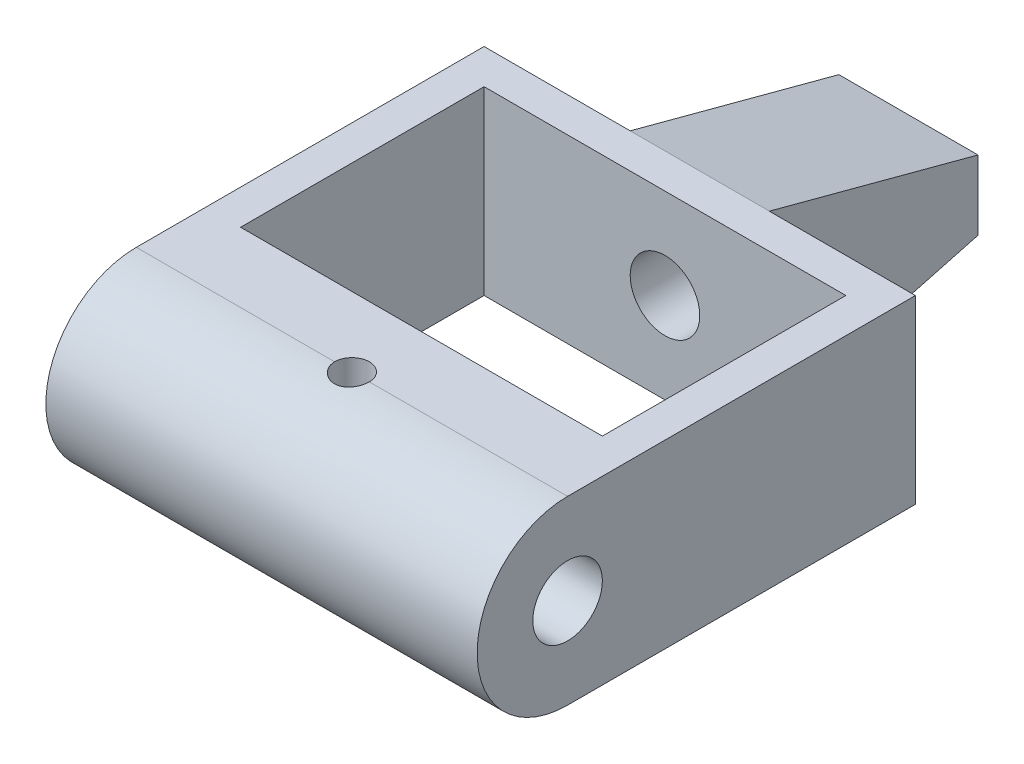
from build123d import *

# Parameters (mm, degrees)
CROQUIS1_R                 = 13
SALIENTE_EXTRUIR1_DEPTH    = 62
CROQUIS2_R                 = 5
CORTAR_EXTRUIR1_DEPTH      = 62
CORTAR_EXTRUIR2_DEPTH      = 62
CORTAR_EXTRUIR2_DEPTH_BACK = 62
CROQUIS3_R                 = 2.5
SALIENTE_EXTRUIR2_START    = -62
SALIENTE_EXTRUIR2_DEPTH    = 62
CROQUIS5_W                 = 52
CROQUIS5_H                 = 35
CORTAR_EXTRUIR4_DEPTH      = 62
CROQUIS6_R                 = 2.5
CORTAR_EXTRUIR5_DEPTH      = 62
CROQUIS7_R                 = 5
CORTAR_EXTRUIR6_DEPTH      = 62
CORTAR_EXTRUIR8_DEPTH      = 62
CORTAR_EXTRUIR8_DEPTH_BACK = 62
CROQUIS8_W                 = 21
CROQUIS8_H                 = 30


with BuildPart() as part:
    # Croquis1 → Saliente-Extruir1 (new body)
    with BuildSketch(Plane(origin=(0, 0, 0), x_dir=(0, 0, -1), z_dir=(1, 0, 0))):
        Circle(CROQUIS1_R)
    extrude(amount=SALIENTE_EXTRUIR1_DEPTH)

    # Croquis2 → Cortar-Extruir1 (cut)
    with BuildSketch(Plane(origin=(62, 0, 0), x_dir=(0, 0, -1), z_dir=(1, 0, 0))):
        Circle(CROQUIS2_R)
    extrude(amount=-CORTAR_EXTRUIR1_DEPTH, mode=Mode.SUBTRACT)

    # Croquis3 → Cortar-Extruir2 (cut, two sides: drawn at the far end of the back side and taken through both)
    with BuildSketch(Plane(origin=(0, 0, 0), x_dir=(1, 0, 0), z_dir=(0, 1, 0)).offset(-CORTAR_EXTRUIR2_DEPTH_BACK)):
        with Locations((31, 0)):
            Circle(CROQUIS3_R)
    extrude(amount=CORTAR_EXTRUIR2_DEPTH + CORTAR_EXTRUIR2_DEPTH_BACK, mode=Mode.SUBTRACT)

    # Croquis4 → Saliente-Extruir2 (add)
    with BuildSketch(Plane(origin=(62, 0, 0), x_dir=(0, 0, -1), z_dir=(1, 0, 0)).offset(SALIENTE_EXTRUIR2_START)):
        with BuildLine():
            Line((50, 13), (0, 13))
            ThreePointArc((0, 13), (9.192388155, 9.192388155), (13, 0))
            ThreePointArc((13, 0), (9.192388155, -9.192388155), (0, -13))
            Line((0, -13), (50, -13))
            Line((50, -13), (80, -5))
            Line((80, -5), (80, 0))
            Line((80, 0), (80, 5))
            Line((80, 5), (50, 13))
        make_face()
    extrude(amount=SALIENTE_EXTRUIR2_DEPTH)

    # Croquis5 → Cortar-Extruir4 (cut)
    with BuildSketch(Plane(origin=(0, 13, 0), x_dir=(1, 0, 0), z_dir=(0, 1, 0))):
        with Locations((31, 27.5)):
            Rectangle(CROQUIS5_W, CROQUIS5_H)
    extrude(amount=-CORTAR_EXTRUIR4_DEPTH, mode=Mode.SUBTRACT)

    # Croquis6 → Cortar-Extruir5 (cut)
    with BuildSketch(Plane(origin=(0, 13, 0), x_dir=(1, 0, 0), z_dir=(0, 1, 0))):
        with Locations((31, 0)):
            Circle(CROQUIS6_R)
    extrude(amount=-CORTAR_EXTRUIR5_DEPTH, mode=Mode.SUBTRACT)

    # Croquis7 → Cortar-Extruir6 (cut)
    with BuildSketch(Plane(origin=(0, 0, -80), x_dir=(-1, 0, 0), z_dir=(0, 0, -1))):
        with Locations((-31, 0)):
            Circle(CROQUIS7_R)
    extrude(amount=-CORTAR_EXTRUIR6_DEPTH, mode=Mode.SUBTRACT)

    # Croquis8 → Cortar-Extruir8 (cut, two sides: drawn at the far end of the back side and taken through both)
    with BuildSketch(Plane(origin=(0, 0, 0), x_dir=(1, 0, 0), z_dir=(0, 1, 0)).offset(-CORTAR_EXTRUIR8_DEPTH_BACK)):
        with Locations((51.5, 65)):
            Rectangle(CROQUIS8_W, CROQUIS8_H)
        with Locations((10.5, 65)):
            Rectangle(CROQUIS8_W, CROQUIS8_H)
    extrude(amount=CORTAR_EXTRUIR8_DEPTH + CORTAR_EXTRUIR8_DEPTH_BACK, mode=Mode.SUBTRACT)


solid = part.part
